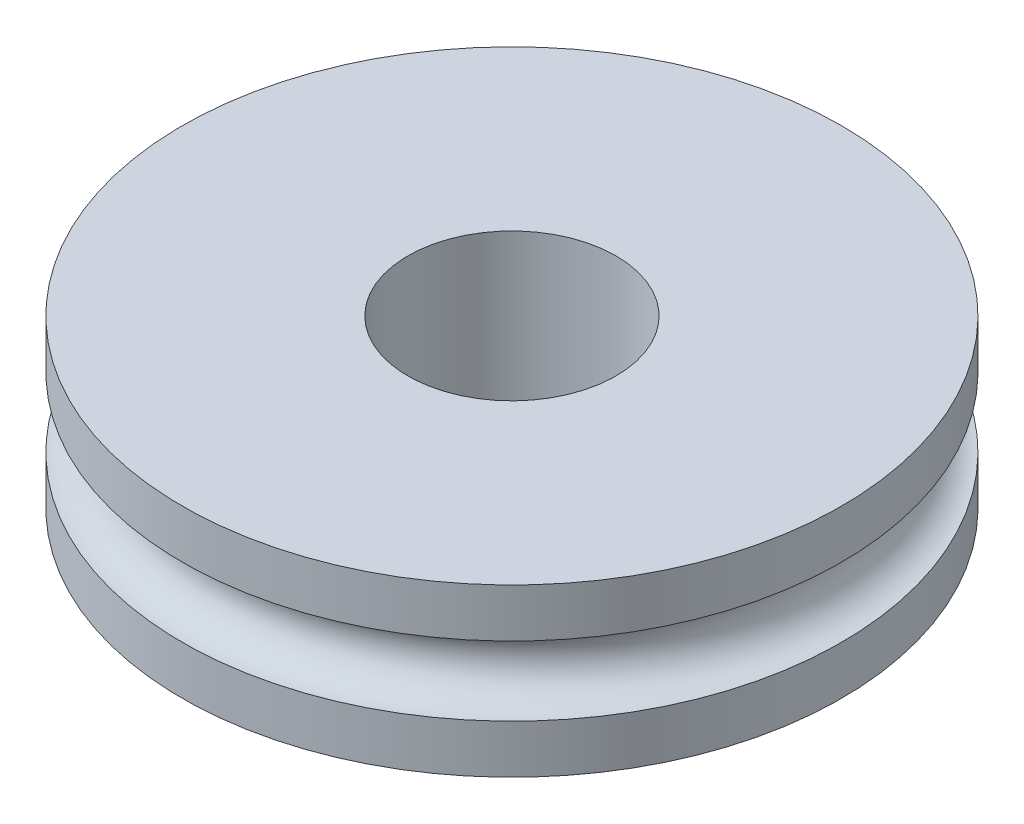
from build123d import *


with BuildPart() as part:
    # Sketch1 → Revolve1 (revolve)
    with BuildSketch(Plane.XY):
        with BuildLine():
            Line((1.5, -1.2), (1.5, 1.2))
            Line((1.5, 1.2), (4.75, 1.2))
            Line((4.75, 1.2), (4.75, 0.5))
            ThreePointArc((4.75, 0.5), (4.25, 0), (4.75, -0.5))
            Line((4.75, -0.5), (4.75, -1.2))
            Line((4.75, -1.2), (1.5, -1.2))
        make_face()
    revolve(axis=Axis((0, 0, 0), (0, 1, 0)))


solid = part.part
